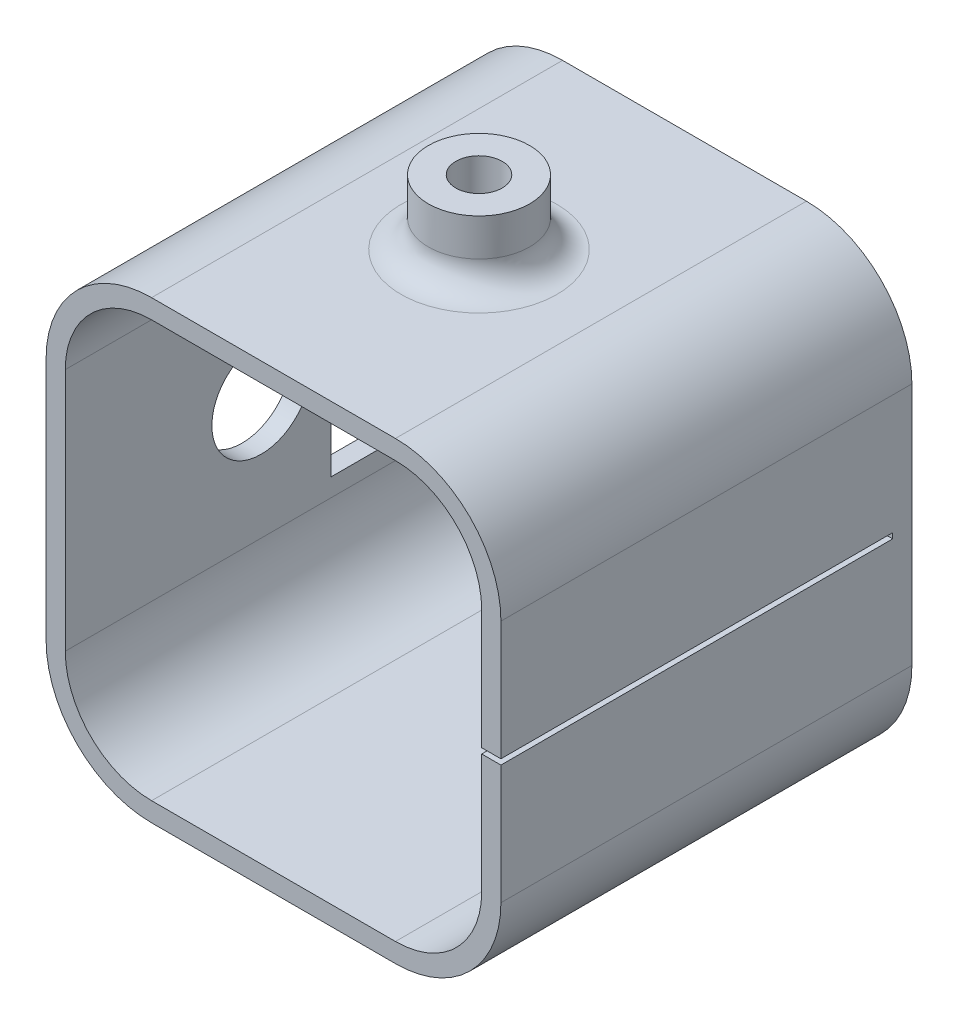
from build123d import *

# Parameters (mm, degrees)
BOSS_EXTRUDE1_DEPTH = 36.322
CUT_EXTRUDE1_REACH  = 61.511
SKETCH2_R           = 4.572
SKETCH2_W           = 6.096
SKETCH2_H           = 19.2532
BOSS_EXTRUDE2_DEPTH = 1.778
CUT_EXTRUDE2_REACH  = 50.379
SKETCH3_R           = 6.858
SKETCH4_R           = 4.69
SKETCH4_R_2         = 2.15
BOSS_EXTRUDE3_DEPTH = 6
FILLET1_R           = 2.54
CUT_EXTRUDE3_REACH  = 53.279
SKETCH5_W           = 5.588
SKETCH5_H           = 10.16
FILLET2_R           = 1.778
SKETCH6_W           = 1.778
SKETCH6_H           = 0.5
CUT_EXTRUDE4_DEPTH  = 36.322


with BuildPart() as part:
    # Sketch1 → Boss-Extrude1 (new body)
    with BuildSketch(Plane.XY):
        with BuildLine():
            Line((-11.304, 21.082), (11.304, 21.082))
            ThreePointArc((11.304, 21.082), (18.218090106, 18.218090106), (21.082, 11.304))
            Line((21.082, 11.304), (21.082, -11.304))
            ThreePointArc((21.082, -11.304), (18.218090106, -18.218090106), (11.304, -21.082))
            Line((11.304, -21.082), (-11.304, -21.082))
            ThreePointArc((-11.304, -21.082), (-18.218090106, -18.218090106), (-21.082, -11.304))
            Line((-21.082, -11.304), (-21.082, 11.304))
            ThreePointArc((-21.082, 11.304), (-18.218090106, 18.218090106), (-11.304, 21.082))
        make_face()
        with BuildLine():
            Line((-11.304, -19.304), (11.304, -19.304))
            ThreePointArc((11.304, -19.304), (16.960854249, -16.960854249), (19.304, -11.304))
            Line((19.304, -11.304), (19.304, 11.304))
            ThreePointArc((19.304, 11.304), (16.960854249, 16.960854249), (11.304, 19.304))
            Line((11.304, 19.304), (-11.304, 19.304))
            ThreePointArc((-11.304, 19.304), (-16.960854249, 16.960854249), (-19.304, 11.304))
            Line((-19.304, 11.304), (-19.304, -11.304))
            ThreePointArc((-19.304, -11.304), (-16.960854249, -16.960854249), (-11.304, -19.304))
        make_face(mode=Mode.SUBTRACT)
    extrude(amount=BOSS_EXTRUDE1_DEPTH)

    # Sketch2 → Cut-Extrude1 (cut, up to next)
    with BuildSketch(Plane.ZY.offset(21.082), mode=Mode.PRIVATE) as cut_extrude1_sk1:
        with Locations(Location((18.161, 0, 0), (0, 0, 270))):
            Circle(SKETCH2_R)
    cut_extrude1_tool1 = extrude(cut_extrude1_sk1.sketch, amount=-CUT_EXTRUDE1_REACH, mode=Mode.PRIVATE) & part.part
    # Sketch2 → Cut-Extrude1 (cut, up to next)
    with BuildSketch(Plane.ZY.offset(21.082), mode=Mode.PRIVATE) as cut_extrude1_sk2:
        with Locations((8.636, 0)):
            Rectangle(SKETCH2_W, SKETCH2_H)
    cut_extrude1_tool2 = extrude(cut_extrude1_sk2.sketch, amount=-CUT_EXTRUDE1_REACH, mode=Mode.PRIVATE) & part.part
    add(cut_extrude1_tool1.solids().sort_by_distance((-21.082, 0, 18.161))[0], mode=Mode.SUBTRACT)
    add(cut_extrude1_tool2.solids().sort_by_distance((-21.082, 0, 8.636))[0], mode=Mode.SUBTRACT)

    # Sketch1_2 → Boss-Extrude2 (add)
    with BuildSketch(Plane.XY):
        with BuildLine():
            ThreePointArc((-21.082, 11.304), (-18.218090106, 18.218090106), (-11.304, 21.082))
            Line((-11.304, 21.082), (11.304, 21.082))
            ThreePointArc((11.304, 21.082), (18.218090106, 18.218090106), (21.082, 11.304))
            Line((21.082, 11.304), (21.082, -11.304))
            ThreePointArc((21.082, -11.304), (18.218090106, -18.218090106), (11.304, -21.082))
            Line((11.304, -21.082), (-11.304, -21.082))
            ThreePointArc((-11.304, -21.082), (-18.218090106, -18.218090106), (-21.082, -11.304))
            Line((-21.082, -11.304), (-21.082, 11.304))
        make_face()
        with BuildLine():
            Line((-19.304, -11.304), (-19.304, 11.304))
            ThreePointArc((-19.304, 11.304), (-16.960854249, 16.960854249), (-11.304, 19.304))
            Line((-11.304, 19.304), (11.304, 19.304))
            ThreePointArc((11.304, 19.304), (16.960854249, 16.960854249), (19.304, 11.304))
            Line((19.304, 11.304), (19.304, -11.304))
            ThreePointArc((19.304, -11.304), (16.960854249, -16.960854249), (11.304, -19.304))
            Line((11.304, -19.304), (-11.304, -19.304))
            ThreePointArc((-11.304, -19.304), (-16.960854249, -16.960854249), (-19.304, -11.304))
        make_face(mode=Mode.SUBTRACT)
        with BuildLine():
            ThreePointArc((-19.304, 11.304), (-16.960854249, 16.960854249), (-11.304, 19.304))
            Line((-11.304, 19.304), (11.304, 19.304))
            ThreePointArc((11.304, 19.304), (16.960854249, 16.960854249), (19.304, 11.304))
            Line((19.304, 11.304), (19.304, -11.304))
            ThreePointArc((19.304, -11.304), (16.960854249, -16.960854249), (11.304, -19.304))
            Line((11.304, -19.304), (-11.304, -19.304))
            ThreePointArc((-11.304, -19.304), (-16.960854249, -16.960854249), (-19.304, -11.304))
            Line((-19.304, -11.304), (-19.304, 11.304))
        make_face()
    extrude(amount=-BOSS_EXTRUDE2_DEPTH)

    # Sketch3 → Cut-Extrude2 (cut, up to next)
    with BuildSketch(Plane(origin=(0, 0, -1.778), x_dir=(-1, 0, 0), z_dir=(0, 0, -1)), mode=Mode.PRIVATE) as cut_extrude2_sk1:
        Circle(SKETCH3_R)
    cut_extrude2_tool1 = extrude(cut_extrude2_sk1.sketch, amount=-CUT_EXTRUDE2_REACH, mode=Mode.PRIVATE) & part.part
    add(cut_extrude2_tool1.solids().sort_by_distance((0, 0, -1.778))[0], mode=Mode.SUBTRACT)

    # Sketch4 → Boss-Extrude3 (add)
    with BuildSketch(Plane(origin=(0, 21.082, 0), x_dir=(1, 0, 0), z_dir=(0, 1, 0))):
        with Locations(Location((0, -17.272, 0), (0, 0, 90))):
            Circle(SKETCH4_R)
        with Locations(Location((0, -17.272, 0), (0, 0, 270))):
            Circle(SKETCH4_R_2, mode=Mode.SUBTRACT)
    boss_extrude3 = extrude(amount=BOSS_EXTRUDE3_DEPTH)

    # Mirror1: Boss-Extrude3 across plane
    add(boss_extrude3.mirror(Plane.ZX))

    # Fillet1
    fillet1_edges = [part.edges().sort_by_distance(p)[0] for p in [
        (0, 21.082, 21.962),
        (0, -21.082, 21.962),
    ]]
    fillet(fillet1_edges, radius=FILLET1_R)

    # Sketch5 → Cut-Extrude3 (cut, up to next)
    with BuildSketch(Plane(origin=(0, 0, -1.778), x_dir=(-1, 0, 0), z_dir=(0, 0, -1)), mode=Mode.PRIVATE) as cut_extrude3_sk1:
        with Locations((-16.51, 0)):
            Rectangle(SKETCH5_W, SKETCH5_H)
    cut_extrude3_tool1 = extrude(cut_extrude3_sk1.sketch, amount=-CUT_EXTRUDE3_REACH, mode=Mode.PRIVATE) & part.part
    add(cut_extrude3_tool1.solids().sort_by_distance((16.51, 0, -1.778))[0], mode=Mode.SUBTRACT)

    # Fillet2
    fillet2_edges = [part.edges().sort_by_distance(p)[0] for p in [
        (13.716, 5.08, -0.889),
        (13.716, -5.08, -0.889),
    ]]
    fillet(fillet2_edges, radius=FILLET2_R)

    # Sketch6 → Cut-Extrude4 (cut)
    with BuildSketch(Plane.XY.offset(36.322)):
        with Locations((20.193, 0)):
            Rectangle(SKETCH6_W, SKETCH6_H)
    extrude(amount=-CUT_EXTRUDE4_DEPTH, mode=Mode.SUBTRACT)


solid = part.part
